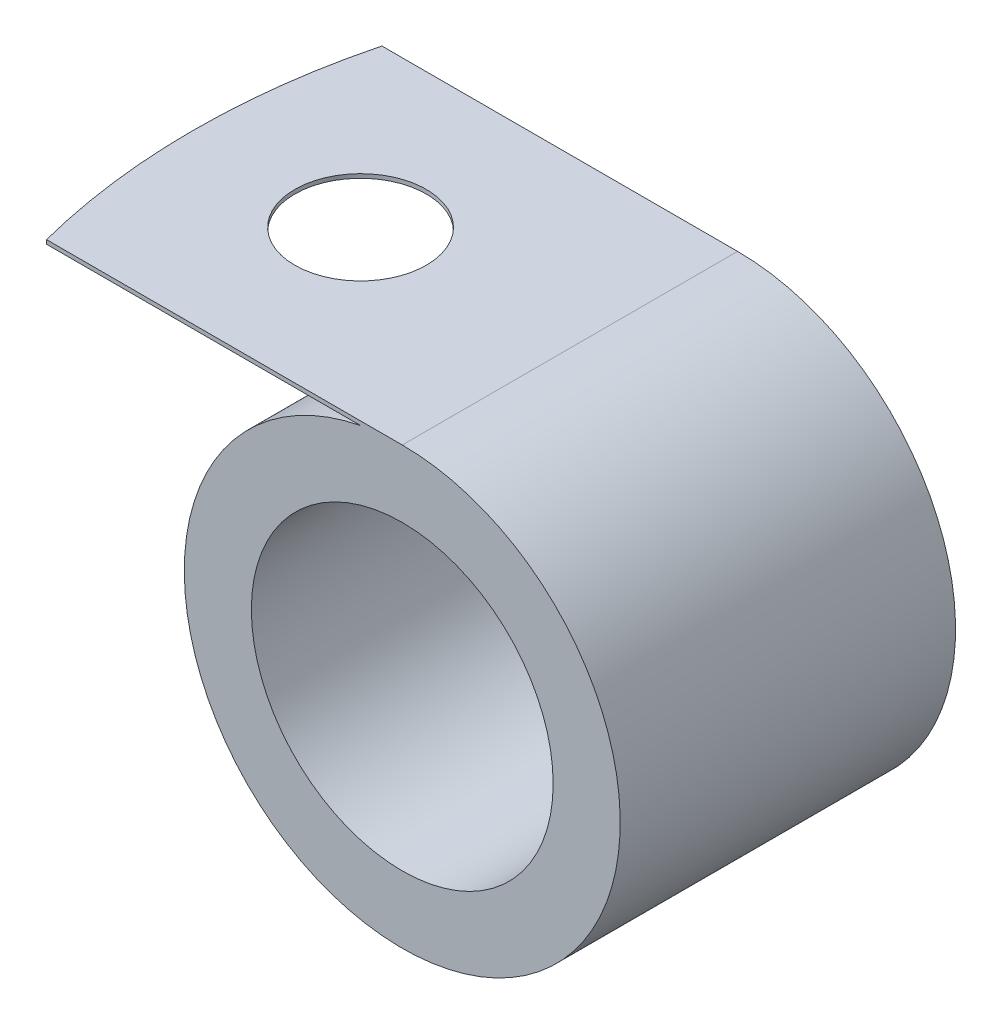
from build123d import *

# Parameters (mm, degrees)
SKETCH1_R           = 8.255
SKETCH1_R_2         = 5.715
BOSS_EXTRUDE1_DEPTH = 6.35
CUT_EXTRUDE1_REACH  = 18.51
SKETCH5_R           = 2.4892


with BuildPart() as part:
    # Sketch1 → Boss-Extrude1 (new body, symmetric)
    with BuildSketch(Plane.XY):
        Circle(SKETCH1_R)
        Circle(SKETCH1_R_2, mode=Mode.SUBTRACT)
        with BuildLine():
            ThreePointArc((-1.578891459, 8.1026), (-0.793114746, 8.216811669), (0, 8.255))
            Line((0, 8.255), (-14.278891459, 8.255))
            Line((-14.278891459, 8.255), (-14.278891459, 8.1026))
            Line((-14.278891459, 8.1026), (-1.578891459, 8.1026))
        make_face()
    extrude(amount=BOSS_EXTRUDE1_DEPTH, both=True)

    # Sketch5 → Cut-Extrude1 (cut, up to next)
    with BuildSketch(Plane(origin=(0, 8.255, 0), x_dir=(1, 0, 0), z_dir=(0, 1, 0)), mode=Mode.PRIVATE) as cut_extrude1_sk1:
        with BuildLine():
            ThreePointArc((-14.278891459, -1.01e-07), (-14.076445751, 3.200508979), (-13.472335708, 6.35))
            Line((-13.472335708, 6.35), (-14.278891459, 6.35))
            Line((-14.278891459, 6.35), (-14.278891459, -1.01e-07))
        make_face()
    cut_extrude1_tool1 = extrude(cut_extrude1_sk1.sketch, amount=-CUT_EXTRUDE1_REACH, mode=Mode.PRIVATE) & part.part
    add(cut_extrude1_tool1.solids().sort_by_distance((-14.037598, 8.255, -4.767585))[0], mode=Mode.SUBTRACT)
    # Sketch5 → Cut-Extrude1 (cut, up to next)
    with BuildSketch(Plane(origin=(0, 8.255, 0), x_dir=(1, 0, 0), z_dir=(0, 1, 0)), mode=Mode.PRIVATE) as cut_extrude1_sk2:
        with BuildLine():
            ThreePointArc((-13.472335708, -6.35), (-14.076445738, -3.200509079), (-14.278891459, -1.01e-07))
            Line((-14.278891459, -1.01e-07), (-14.278891459, -6.35))
            Line((-14.278891459, -6.35), (-13.472335708, -6.35))
        make_face()
    cut_extrude1_tool2 = extrude(cut_extrude1_sk2.sketch, amount=-CUT_EXTRUDE1_REACH, mode=Mode.PRIVATE) & part.part
    add(cut_extrude1_tool2.solids().sort_by_distance((-14.037598, 8.255, 4.767585))[0], mode=Mode.SUBTRACT)
    # Sketch5 → Cut-Extrude1 (cut, up to next)
    with BuildSketch(Plane(origin=(0, 8.255, 0), x_dir=(1, 0, 0), z_dir=(0, 1, 0)), mode=Mode.PRIVATE) as cut_extrude1_sk3:
        with Locations((-7.928891459, 0)):
            Circle(SKETCH5_R)
    cut_extrude1_tool3 = extrude(cut_extrude1_sk3.sketch, amount=-CUT_EXTRUDE1_REACH, mode=Mode.PRIVATE) & part.part
    add(cut_extrude1_tool3.solids().sort_by_distance((-7.928891, 8.255, 0))[0], mode=Mode.SUBTRACT)


solid = part.part
